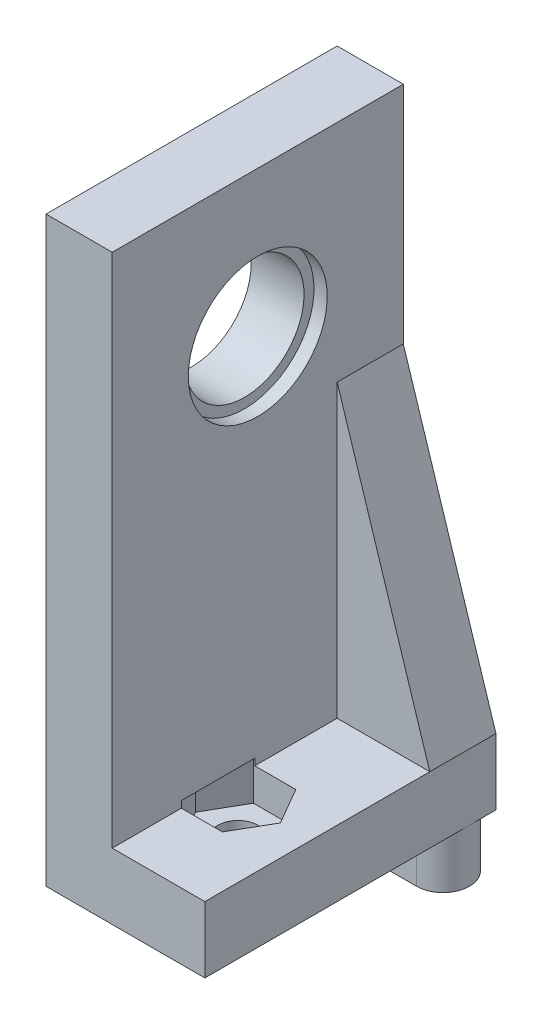
from build123d import *

# Parameters (mm, degrees)
SKETCH_1_W               = 40
SKETCH_1_H               = 44
SKETCH_1_R               = 4.5
EXTRUDE_1_DEPTH          = 5
SKETCH_2_R               = 5.25
CUT_EXTRUDE_1_DEPTH      = 1
SKETCH_3_W               = 18
SKETCH_3_H               = 44
CUT_EXTRUDE_2_DEPTH      = 6
SKETCH_4_R               = 4.5
EXTRUDE_2_DEPTH          = 5
SKETCH_5_W               = 22
SKETCH_5_H               = 5
EXTRUDE_3_DEPTH          = 7
EXTRUDE_4_DEPTH          = 4
SKETCH_7_R               = 1.5
CUT_EXTRUDE_3_DEPTH      = 5
CUT_EXTRUDE_4_DEPTH      = 0.5
CUT_EXTRUDE_4_DEPTH_BACK = 2.5
EXTRUDE_5_DEPTH          = 5


with BuildPart() as part:
    # 草图1 → 凸台-拉伸1 (new body)
    with BuildSketch(Plane(origin=(0, 0, 0), x_dir=(0, 0, -1), z_dir=(1, 0, 0))):
        with Locations((9, -5)):
            Rectangle(SKETCH_1_W, SKETCH_1_H)
        Circle(SKETCH_1_R, mode=Mode.SUBTRACT)
        with Locations((18, 6)):
            Circle(SKETCH_1_R, mode=Mode.SUBTRACT)
        with Locations((11.543885882, -13.351449313)):
            Circle(SKETCH_1_R, mode=Mode.SUBTRACT)
    extrude(amount=EXTRUDE_1_DEPTH)

    # 草图2 → 切除-拉伸1 (cut)
    with BuildSketch(Plane.ZY.offset(-5)):
        with Locations((-18, 6)):
            Circle(SKETCH_2_R)
        Circle(SKETCH_2_R)
    extrude(amount=CUT_EXTRUDE_1_DEPTH, mode=Mode.SUBTRACT)

    # 草图3 → 切除-拉伸2 (cut, through all)
    with BuildSketch(Plane(origin=(5, 0, 0), x_dir=(0, 0, -1), z_dir=(1, 0, 0))):
        with Locations((-2, -5)):
            Rectangle(SKETCH_3_W, SKETCH_3_H)
    extrude(amount=-CUT_EXTRUDE_2_DEPTH, mode=Mode.SUBTRACT)

    # 草图4 → 凸台-拉伸2 (add, through all)
    with BuildSketch(Plane(origin=(5, 0, 0), x_dir=(0, 0, -1), z_dir=(1, 0, 0))):
        with Locations((11.543885882, -13.351449313)):
            Circle(SKETCH_4_R)
    extrude(amount=-EXTRUDE_2_DEPTH)

    # 草图5 → 凸台-拉伸3 (add)
    with BuildSketch(Plane(origin=(5, 0, 0), x_dir=(0, 0, -1), z_dir=(1, 0, 0))):
        with Locations((18, -24.5)):
            Rectangle(SKETCH_5_W, SKETCH_5_H)
    extrude(amount=EXTRUDE_3_DEPTH)

    # 草图6 → 凸台-拉伸4 (add)
    with BuildSketch(Plane.XZ.offset(27)):
        with BuildLine():
            Line((0, -29), (10, -29))
            ThreePointArc((10, -29), (12, -27), (10, -25))
            Line((10, -25), (0, -25))
            Line((0, -25), (0, -29))
        make_face()
    extrude(amount=EXTRUDE_4_DEPTH)

    # 草图7 → 切除-拉伸3 (cut)
    with BuildSketch(Plane.XZ.offset(27)):
        with Locations((6.5, -15)):
            Circle(SKETCH_7_R)
    extrude(amount=-CUT_EXTRUDE_3_DEPTH, mode=Mode.SUBTRACT)

    # 草图8 → 切除-拉伸4 (cut, two sides)
    with BuildSketch(Plane(origin=(0, -22, 0), x_dir=(-1, 0, 0), z_dir=(0, 1, 0))) as cut_extrude_4_sk:
        Polygon((-9.704293994, -15), (-8.102146997, -17.775), (-4.897853003, -17.775), (-3.295706006, -15), (-4.897853003, -12.225), (-8.102146997, -12.225), align=None)
    extrude(amount=CUT_EXTRUDE_4_DEPTH, mode=Mode.SUBTRACT)
    extrude(cut_extrude_4_sk.sketch, amount=-CUT_EXTRUDE_4_DEPTH_BACK, mode=Mode.SUBTRACT)

    # 草图9 → 凸台-拉伸5 (add)
    with BuildSketch(Plane(origin=(0, 0, -29), x_dir=(-1, 0, 0), z_dir=(0, 0, -1))):
        Polygon((-5, -22), (-12, -22), (-5, 0), align=None)
    extrude(amount=-EXTRUDE_5_DEPTH)


solid = part.part
